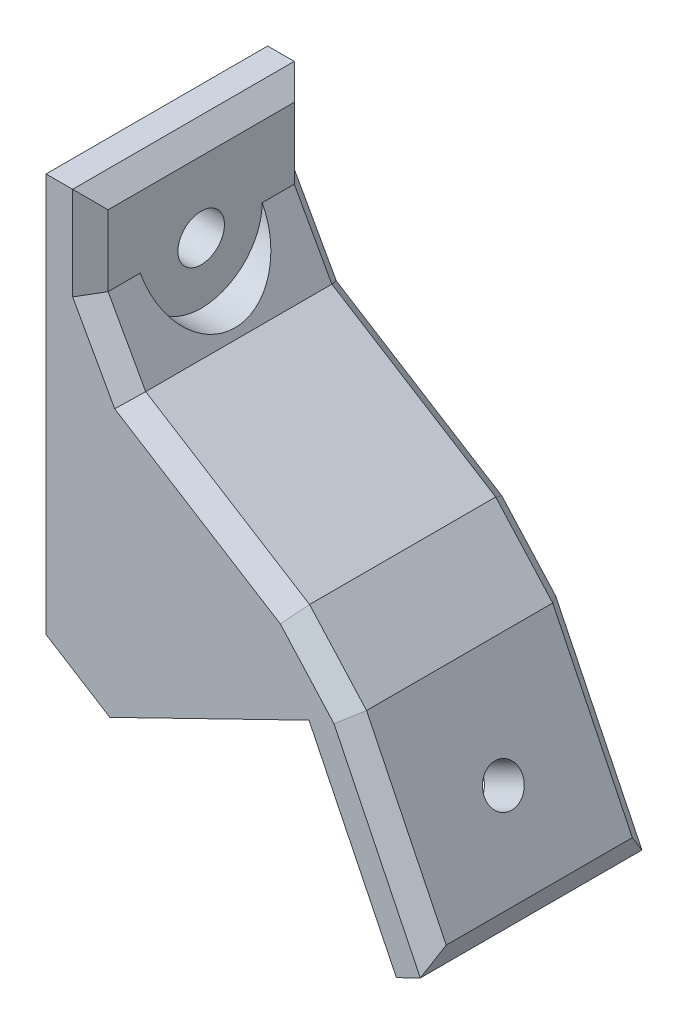
from build123d import *

# Parameters (mm, degrees)
BOSS_EXTRU_1_DEPTH      = 20
ESQUISSE2_W             = 20
ESQUISSE2_H             = 20
BOSS_EXTRU_2_DEPTH      = 4
ESQUISSE3_W             = 20
ESQUISSE3_H             = 20
BOSS_EXTRU_3_DEPTH      = 4
ESQUISSE4_W             = 4
ESQUISSE4_H             = 16
BOSS_EXTRU_4_DEPTH      = 20
CHANFREIN1_SIZE         = 4
ESQUISSE5_R             = 2.1
ENL_V_MAT_EXTRU_1_DEPTH = 36.215222341
ESQUISSE6_R             = 5.5
ENL_V_MAT_EXTRU_2_DEPTH = 32.215222341
D_GAGEMENT_41_D         = 3.4544
D_GAGEMENT_41_DEPTH     = 10
D_GAGEMENT_41_TIP       = 1.037806461
CHANFREIN2_SIZE         = 1.6


with BuildPart() as part:
    # Esquisse1 → Boss.-Extru.1 (new body)
    with BuildSketch(Plane.XY):
        Polygon((0, 0), (0, 20), (17.975880926, 8.767422936), align=None)
    extrude(amount=BOSS_EXTRU_1_DEPTH)

    # Esquisse2 → Boss.-Extru.2 (add)
    with BuildSketch(Plane.ZY):
        with Locations((10, 10)):
            Rectangle(ESQUISSE2_W, ESQUISSE2_H)
    extrude(amount=BOSS_EXTRU_2_DEPTH)

    # Esquisse3 → Boss.-Extru.3 (add)
    with BuildSketch(Plane(origin=(0, 0, 0), x_dir=(0.898794046, 0.438371147, 0), z_dir=(0.438371147, -0.898794046, 0))):
        with Locations((10, 10)):
            Rectangle(ESQUISSE3_W, ESQUISSE3_H)
    extrude(amount=BOSS_EXTRU_3_DEPTH)

    # Esquisse4 → Boss.-Extru.4 (add)
    with BuildSketch(Plane.XY.offset(20)):
        with Locations((-2, 28)):
            Rectangle(ESQUISSE4_W, ESQUISSE4_H)
        Polygon((0, 24), (0, 20), (17.975880926, 8.767422936), (21.571057111, 10.520907523), align=None)
        Polygon((31.215222341, -9.252561496), (21.571057111, 10.520907523), (17.975880926, 8.767422936), (19.729365513, 5.172246751), (27.620046155, -11.006046083), align=None)
        Polygon((0, 0), (-4, 0), (1.753484587, -3.595176185), align=None)
    extrude(amount=-BOSS_EXTRU_4_DEPTH)

    # Chanfrein1
    chanfrein1_edges = [part.edges().sort_by_distance(p)[0] for p in [
        (0, 24, 10),
        (21.571057111, 10.520907523, 10),
    ]]
    chamfer(chanfrein1_edges, length=CHANFREIN1_SIZE)

    # Esquisse5 → Enlèv. mat.-Extru.1 (cut, through all)
    with BuildSketch(Plane.ZY.offset(4)):
        with Locations((10, 28)):
            Circle(ESQUISSE5_R)
    extrude(amount=-ENL_V_MAT_EXTRU_1_DEPTH, mode=Mode.SUBTRACT)

    # Esquisse6 → Enlèv. mat.-Extru.2 (cut, through all)
    with BuildSketch(Plane(origin=(0, 0, 0), x_dir=(0, 0, -1), z_dir=(1, 0, 0))):
        with Locations((-10, 28)):
            Circle(ESQUISSE6_R)
    extrude(amount=ENL_V_MAT_EXTRU_2_DEPTH, mode=Mode.SUBTRACT)

    # Dégagement #41
    with Locations(Plane(origin=(21.571057111, 10.520907523, 0), x_dir=(0, 0, -1), z_dir=(0.898794046, 0.438371147, 0))):
        with Locations((-10, -13)):
            Hole(D_GAGEMENT_41_D / 2, depth=D_GAGEMENT_41_DEPTH)
            with Locations((0, 0, -(D_GAGEMENT_41_DEPTH + D_GAGEMENT_41_TIP / 2))):  # 118° drill point
                Cone(0, D_GAGEMENT_41_D / 2, D_GAGEMENT_41_TIP, mode=Mode.SUBTRACT)

    # Chanfrein2
    chanfrein2_edges = [part.edges().sort_by_distance(p)[0] for p in [
        (0, 36, 10),
        (27.269882019, -1.163415079, 0),
        (31.215222341, -9.252561496, 10),
        (27.269882019, -1.163415079, 20),
        (10.785528556, 17.260453761, 20),
        (10.785528556, 17.260453761, 0),
        (0, 32, 20),
        (0, 32, 0),
        (20.751703212, 9.783157959, 20),
        (20.751703212, 9.783157959, 0),
        (1.696096192, 24.940161472, 20),
        (1.696096192, 24.940161472, 0),
    ]]
    chamfer(chanfrein2_edges, length=CHANFREIN2_SIZE)


solid = part.part
